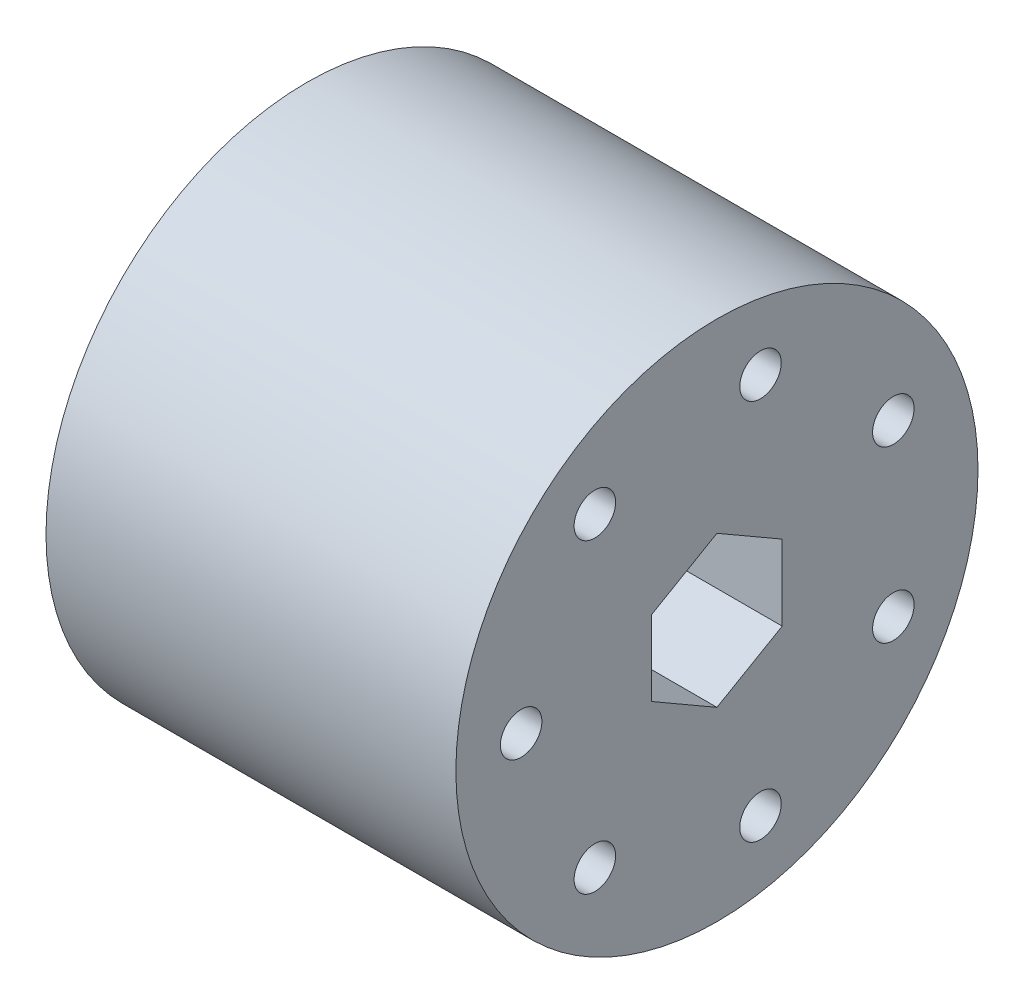
from build123d import *

# Parameters (mm, degrees)
SKETCH2_R                  = 25.4
BOSS_EXTRUDE1_DEPTH        = 39.878
TAP_DRILL_FOR_10_32_TAP1_D = 4.0386


with BuildPart() as part:
    # Sketch2 → Boss-Extrude1 (new body)
    with BuildSketch(Plane.YZ):
        Circle(SKETCH2_R)
        Polygon((3.666174209, 6.35), (-3.666174209, 6.35), (-7.332348419, 0), (-3.666174209, -6.35), (3.666174209, -6.35), (7.332348419, 0), align=None, mode=Mode.SUBTRACT)
    extrude(amount=BOSS_EXTRUDE1_DEPTH)

    # Tap Drill for #10-32 Tap1 (through all)
    with Locations(Plane.YZ.offset(39.878)):
        with Locations((-14.893889741, 11.877480725), (0, 19.05), (14.893889741, 11.877480725), (18.572376727, -4.239023792), (8.26548523, -17.163456934), (-8.26548523, -17.163456934), (-18.572376727, -4.239023792)):
            Hole(TAP_DRILL_FOR_10_32_TAP1_D / 2)


solid = part.part
